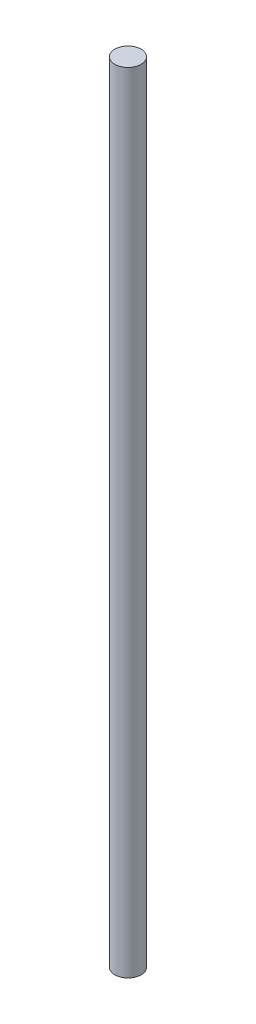
from build123d import *

# Parameters (mm, degrees)
SKETCH1_R           = 4
BOSS_EXTRUDE1_DEPTH = 240


with BuildPart() as part:
    # Sketch1 → Boss-Extrude1 (new body)
    with BuildSketch(Plane(origin=(0, 0, 0), x_dir=(1, 0, 0), z_dir=(0, 1, 0))):
        with Locations(Location((0, 0, 0), (0, 0, 270))):  # turned: the seam where the file's is
            Circle(SKETCH1_R)
    extrude(amount=BOSS_EXTRUDE1_DEPTH)


solid = part.part
